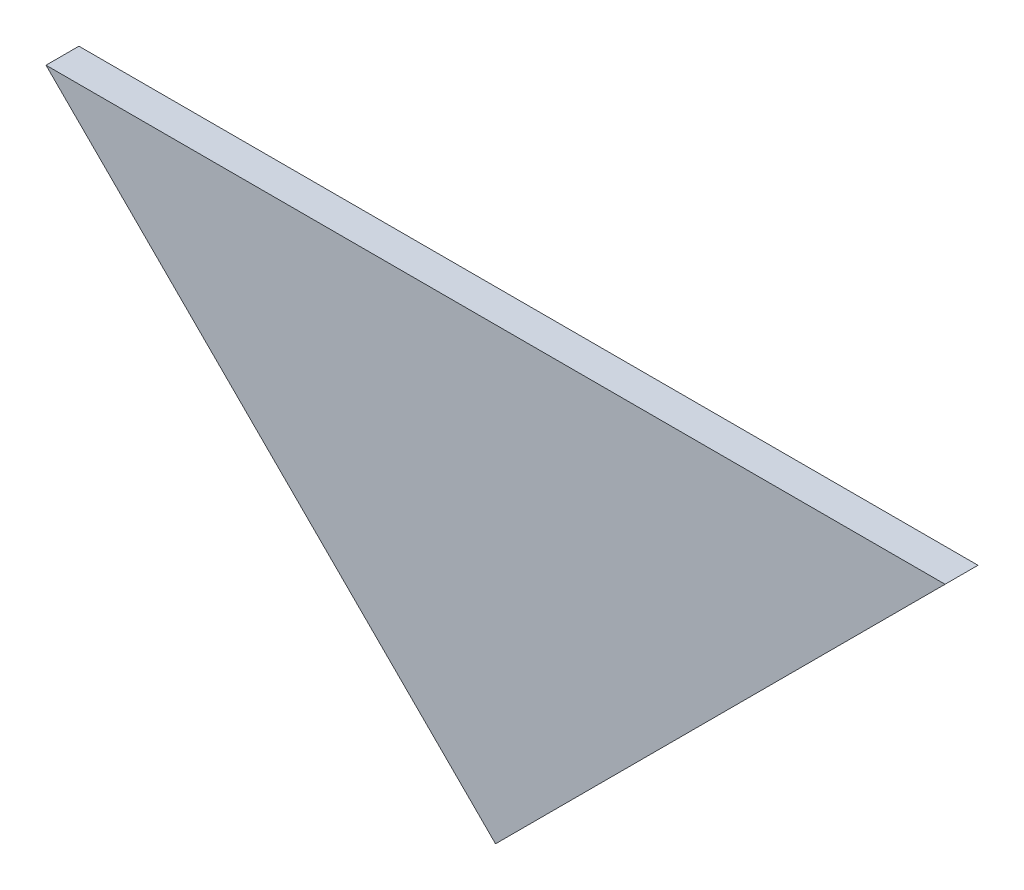
from build123d import *

# Parameters (mm, degrees)
BOSS_EXTRUDE1_DEPTH = 1.5


with BuildPart() as part:
    # Sketch1 → Boss-Extrude1 (new body, symmetric)
    with BuildSketch(Plane.XY.offset(113.704878)):
        Polygon((40.966000127, -116.244878), (-40.966000127, -116.244878), (0, -157.210878127), align=None)
    extrude(amount=BOSS_EXTRUDE1_DEPTH, both=True)


solid = part.part
